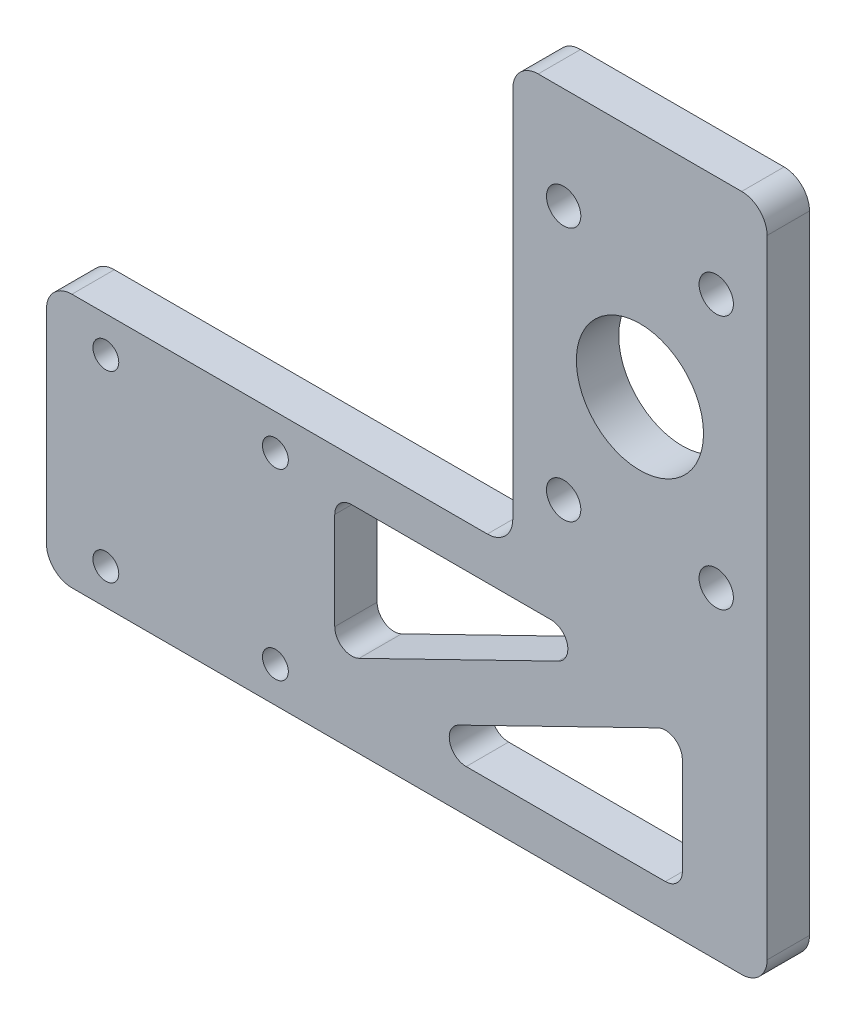
from build123d import *

# Parameters (mm, degrees)
EXTRUDE_1_DEPTH          = 5
SKETCH_3_R               = 2.025
CUT_EXTRUDE_1_DEPTH      = 1
CUT_EXTRUDE_1_DEPTH_BACK = 6
FILLET_1_R               = 3
SKETCH_4_R               = 1.525
CUT_EXTRUDE_2_DEPTH      = 1
CUT_EXTRUDE_2_DEPTH_BACK = 6
CUT_EXTRUDE_3_DEPTH      = 6
FILLET_2_R               = 2
SKETCH_8_R               = 7.5
CUT_EXTRUDE_4_DEPTH      = 5


with BuildPart() as part:
    # 草图1 → 凸台-拉伸1 (new body)
    with BuildSketch(Plane.XY):
        Polygon((0, 0), (-55, 0), (-55, -30), (30, -30), (30, 50), (0, 50), align=None)
    extrude(amount=EXTRUDE_1_DEPTH)

    # 草图3 → 切除-拉伸1 (cut, two sides)
    with BuildSketch(Plane(origin=(0, 0, 0), x_dir=(-1, 0, 0), z_dir=(0, 0, -1))) as cut_extrude_1_sk:
        with Locations((-24, 38)):
            Circle(SKETCH_3_R)
        with Locations((-6, 38)):
            Circle(SKETCH_3_R)
        with Locations((-24, 8)):
            Circle(SKETCH_3_R)
        with Locations((-6, 8)):
            Circle(SKETCH_3_R)
    extrude(amount=CUT_EXTRUDE_1_DEPTH, mode=Mode.SUBTRACT)
    extrude(cut_extrude_1_sk.sketch, amount=-CUT_EXTRUDE_1_DEPTH_BACK, mode=Mode.SUBTRACT)

    # 圆角1
    fillet_1_edges = [part.edges().sort_by_distance(p)[0] for p in [
        (0, 50, 2.5),
        (30, 50, 2.5),
        (30, -30, 2.5),
        (-55, -30, 2.5),
        (-55, 0, 2.5),
        (0, 0, 2.5),
    ]]
    fillet(fillet_1_edges, radius=FILLET_1_R)

    # 草图4 → 切除-拉伸2 (cut, two sides)
    with BuildSketch(Plane.XY.offset(5)) as cut_extrude_2_sk:
        with Locations((-48, -25.8)):
            Circle(SKETCH_4_R)
        with Locations((-48, -4.2)):
            Circle(SKETCH_4_R)
        with Locations((-28, -4.2)):
            Circle(SKETCH_4_R)
        with Locations((-28, -25.8)):
            Circle(SKETCH_4_R)
    extrude(amount=CUT_EXTRUDE_2_DEPTH, mode=Mode.SUBTRACT)
    extrude(cut_extrude_2_sk.sketch, amount=-CUT_EXTRUDE_2_DEPTH_BACK, mode=Mode.SUBTRACT)

    # 草图7 → 切除-拉伸3 (cut, through all)
    with BuildSketch(Plane.XY.offset(5)):
        Polygon((13.157303163, -5), (-21, -5), (-21, -21.662099104), align=None)
        Polygon((20, -25), (20, -8.337900896), (-14.157303163, -25), align=None)
    extrude(amount=-CUT_EXTRUDE_3_DEPTH, mode=Mode.SUBTRACT)

    # 圆角2
    fillet_2_edges = [part.edges().sort_by_distance(p)[0] for p in [
        (-14.157303163, -25, 2.5),
        (20, -8.337900896, 2.5),
        (20, -25, 2.5),
        (-21, -21.662099104, 2.5),
        (-21, -5, 2.5),
        (13.157303163, -5, 2.5),
    ]]
    fillet(fillet_2_edges, radius=FILLET_2_R)

    # 草图8 → 切除-拉伸4 (cut)
    with BuildSketch(Plane.XY.offset(5)):
        with Locations((15, 23)):
            Circle(SKETCH_8_R)
    extrude(amount=-CUT_EXTRUDE_4_DEPTH, mode=Mode.SUBTRACT)


solid = part.part
